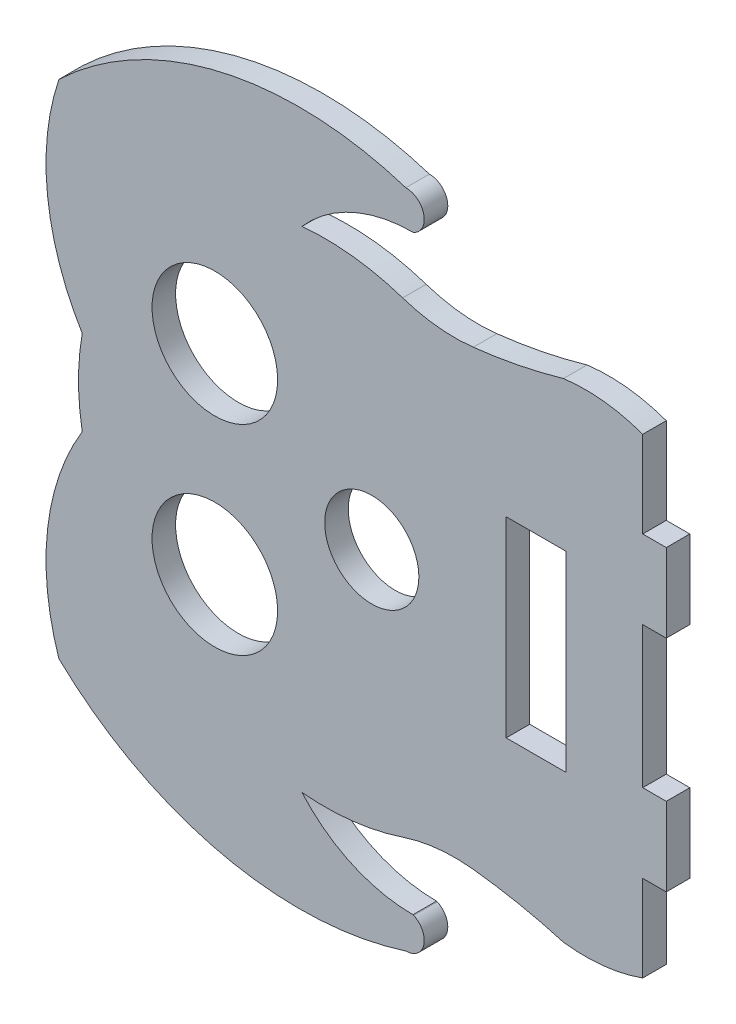
from build123d import *

# Parameters (mm, degrees)
SKETCH2_R           = 8
SKETCH2_R_2         = 6
SKETCH2_W           = 7.6
SKETCH2_H           = 24.4
BOSS_EXTRUDE1_DEPTH = 3


with BuildPart() as part:
    # Sketch2 → Boss-Extrude1 (new body)
    with BuildSketch(Plane.XY):
        with BuildLine():
            Line((81.032103119, 50.181312), (81.032103119, 60.181312))
            Line((81.032103119, 60.181312), (78.032103119, 60.181312))
            Line((78.032103119, 60.181312), (78.032103119, 71.181312))
            ThreePointArc((78.032103119, 71.181312), (73.050090858, 72.33654353), (67.936161846, 72.284235691))
            ThreePointArc((67.936161846, 72.284235691), (62.235942644, 70.892785416), (56.438402104, 69.988818319))
            ThreePointArc((56.438402104, 69.988818319), (51.886102873, 69.971964975), (47.437133801, 70.93653043))
            ThreePointArc((47.437133801, 70.93653043), (41.102316828, 72.343050119), (34.613643935, 72.416041905))
            ThreePointArc((34.613643935, 72.416041905), (40.990344282, 77.154811793), (48.755286163, 78.83526559))
            ThreePointArc((48.755286163, 78.83526559), (48.80614848, 78.851120911), (48.85704212, 78.866875402))
            ThreePointArc((48.85704212, 78.866875402), (50.134187725, 81.487874692), (47.847872498, 83.297156554))
            ThreePointArc((47.847872498, 83.297156554), (24.351235249, 84.294658733), (3.641458375, 73.150507154))
            ThreePointArc((3.641458375, 73.150507154), (2.19654611, 59.548103084), (6.61028157, 46.600821237))
            ThreePointArc((6.61028157, 46.600821237), (6.138572184, 41.181312), (6.61028157, 35.761802763))
            ThreePointArc((6.61028157, 35.761802763), (2.19654611, 22.814520916), (3.641458375, 9.212116846))
            ThreePointArc((3.641458375, 9.212116846), (24.351235249, -1.932034733), (47.847872498, -0.934532554))
            ThreePointArc((47.847872498, -0.934532554), (50.134187725, 0.874749308), (48.85704212, 3.495748598))
            ThreePointArc((48.85704212, 3.495748598), (48.80614848, 3.511503089), (48.755286163, 3.52735841))
            ThreePointArc((48.755286163, 3.52735841), (40.990344282, 5.207812207), (34.613643935, 9.946582095))
            ThreePointArc((34.613643935, 9.946582095), (41.102316828, 10.019573881), (47.437133801, 11.42609357))
            ThreePointArc((47.437133801, 11.42609357), (51.886102873, 12.390659025), (56.438402104, 12.373805681))
            ThreePointArc((56.438402104, 12.373805681), (62.235942644, 11.469838584), (67.936161846, 10.078388309))
            ThreePointArc((67.936161846, 10.078388309), (73.050090858, 10.02608047), (78.032103119, 11.181312))
            Line((78.032103119, 11.181312), (78.032103119, 22.181312))
            Line((78.032103119, 22.181312), (81.032103119, 22.181312))
            Line((81.032103119, 22.181312), (81.032103119, 32.181312))
            Line((81.032103119, 32.181312), (78.032103119, 32.181312))
            Line((78.032103119, 32.181312), (78.032103119, 50.181312))
            Line((78.032103119, 50.181312), (81.032103119, 50.181312))
        make_face()
        with Locations((23.507028058, 53.931312)):
            Circle(SKETCH2_R, mode=Mode.SUBTRACT)
        with Locations((43.507028058, 41.181312)):
            Circle(SKETCH2_R_2, mode=Mode.SUBTRACT)
        with Locations((23.507028058, 28.431312)):
            Circle(SKETCH2_R, mode=Mode.SUBTRACT)
        with Locations((64.432028058, 41.181312)):
            Rectangle(SKETCH2_W, SKETCH2_H, mode=Mode.SUBTRACT)
    extrude(amount=BOSS_EXTRUDE1_DEPTH)


solid = part.part
